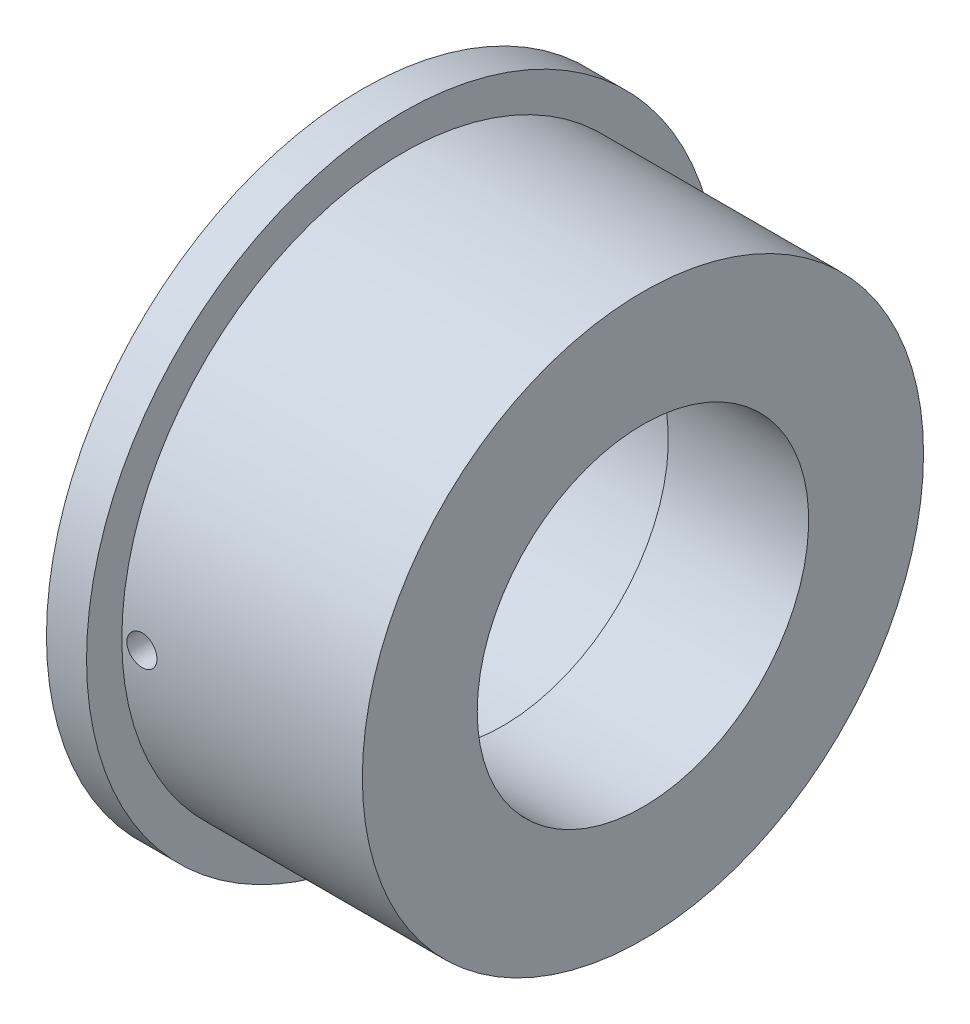
from build123d import *

# Parameters (mm, degrees)
SKETCH2_R               = 2.38125
CUT_EXTRUDE1_DEPTH      = 51.038
CUT_EXTRUDE1_DEPTH_BACK = 51.038


with BuildPart() as part:
    # Sketch1 → Revolve1 (revolve)
    with BuildSketch(Plane.XY):
        Polygon((-38.1, -44.45), (0, -44.45), (0, -26.2509), (-22.225, -26.2509), (-22.225, -30.099), (-44.45, -30.2895), (-44.45, -34.3535), (-44.45, -50.038), (-38.1, -50.038), align=None)
    revolve(axis=Axis((-44.45, 0, 0), (1, 0, 0)))

    # Sketch2 → Cut-Extrude1 (cut, two sides)
    with BuildSketch(Plane.XY) as cut_extrude1_sk:
        with Locations((-34.925, 0)):
            Circle(SKETCH2_R)
    extrude(amount=CUT_EXTRUDE1_DEPTH, mode=Mode.SUBTRACT)
    extrude(cut_extrude1_sk.sketch, amount=-CUT_EXTRUDE1_DEPTH_BACK, mode=Mode.SUBTRACT)


solid = part.part
